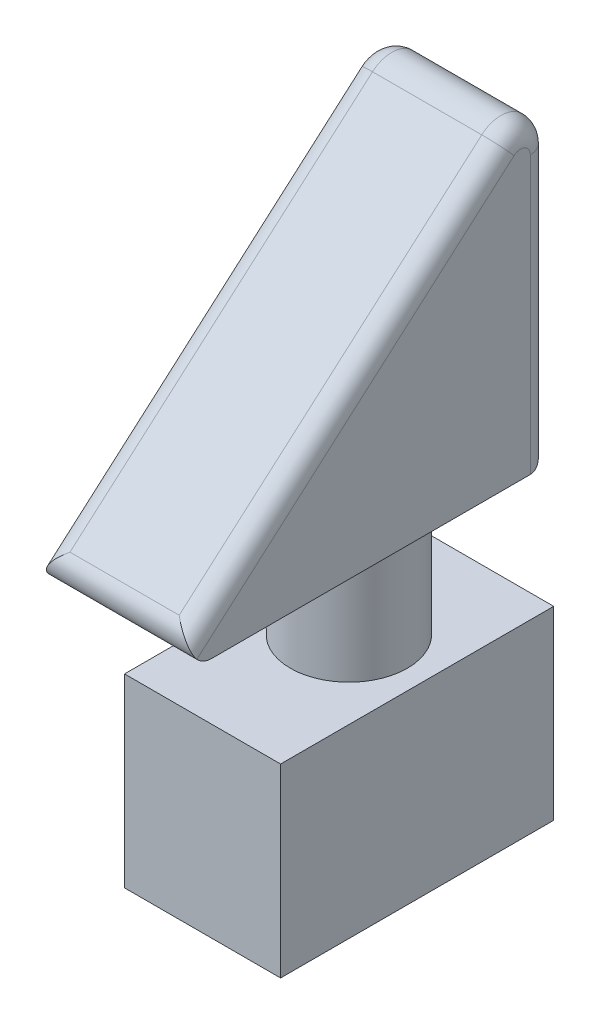
from build123d import *

# Parameters (mm, degrees)
BOSS_EXTRUDE1_DEPTH = 15.2
SKETCH2_R           = 6
BOSS_EXTRUDE2_DEPTH = 12.5
SKETCH3_W           = 16
SKETCH3_H           = 28
BOSS_EXTRUDE3_DEPTH = 19
FILLET1_R           = 3
FILLET2_R           = 2


with BuildPart() as part:
    # Sketch1 → Boss-Extrude1 (new body)
    with BuildSketch(Plane(origin=(0, 0, 0), x_dir=(0, 0, -1), z_dir=(1, 0, 0))):
        Polygon((0, 0), (-40, 0), (0, 35), align=None)
    extrude(amount=BOSS_EXTRUDE1_DEPTH)

    # Sketch2 → Boss-Extrude2 (add)
    with BuildSketch(Plane.XZ):
        with Locations((7.6, 13)):
            Circle(SKETCH2_R)
    extrude(amount=BOSS_EXTRUDE2_DEPTH)

    # Sketch3 → Boss-Extrude3 (add)
    with BuildSketch(Plane.XZ.offset(12.5)):
        with Locations((7.6, 14)):
            Rectangle(SKETCH3_W, SKETCH3_H)
    extrude(amount=BOSS_EXTRUDE3_DEPTH)

    # Fillet1
    fillet1_edges = [part.edges().sort_by_distance(p)[0] for p in [
        (7.6, 35, 0),
    ]]
    fillet(fillet1_edges, radius=FILLET1_R)

    # Fillet2
    fillet2_edges = [part.edges().sort_by_distance(p)[0] for p in [
        (0, 15.323212702, 22.487756912),
        (15.2, 15.323212702, 22.487756912),
        (0, 31.120594062, 1.760351153),
        (15.2, 31.120594062, 1.760351153),
        (15.2, 14.19434766, 0),
        (0, 14.19434766, 0),
        (7.6, 0, 0),
        (7.6, 0, 40),
    ]]
    fillet(fillet2_edges, radius=FILLET2_R)


solid = part.part
